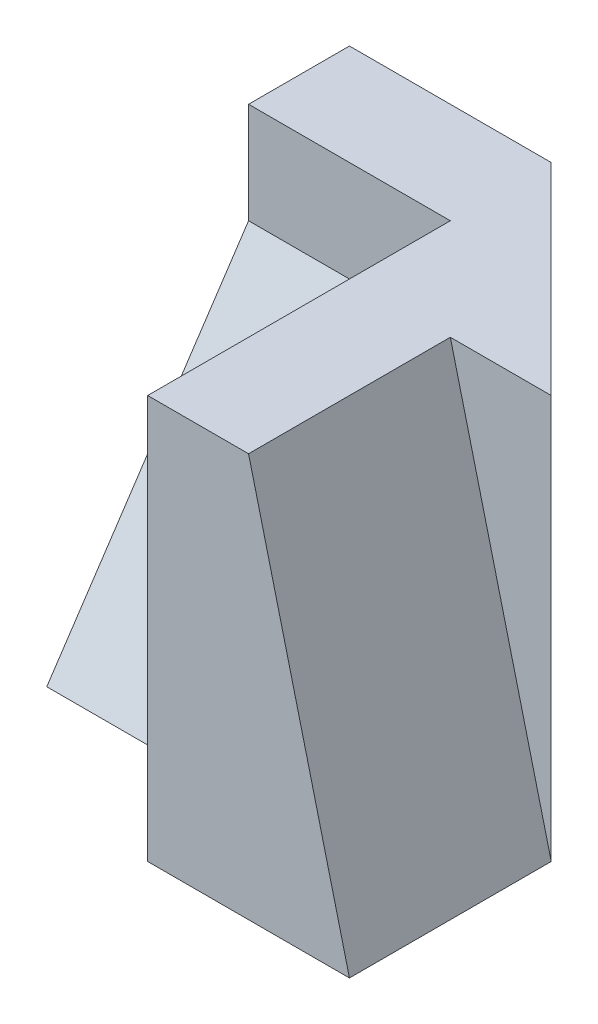
from build123d import *

# Parameters (mm, degrees)
BOSS_EXTRUDE1_DEPTH = 4
CUT_EXTRUDE2_DEPTH  = 2
CUT_EXTRUDE3_DEPTH  = 2


with BuildPart() as part:
    # Sketch1 → Boss-Extrude1 (new body)
    with BuildSketch(Plane(origin=(0, 0, 0), x_dir=(1, 0, 0), z_dir=(0, 1, 0))):
        Polygon((0, 0), (2, 0), (2, 2), (0, 4), (-2, 4), (-2, 1), (0, 1), align=None)
    extrude(amount=BOSS_EXTRUDE1_DEPTH)

    # Sketch3 → Cut-Extrude2 (cut)
    with BuildSketch(Plane.XY):
        Polygon((1, 4), (2, 0), (2, 4), align=None)
    extrude(amount=-CUT_EXTRUDE2_DEPTH, mode=Mode.SUBTRACT)

    # Sketch4 → Cut-Extrude3 (cut)
    with BuildSketch(Plane.ZY.offset(2)):
        Polygon((-1, 4), (-3, 4), (-3, 3), (-1, 0), align=None)
    extrude(amount=-CUT_EXTRUDE3_DEPTH, mode=Mode.SUBTRACT)


solid = part.part
